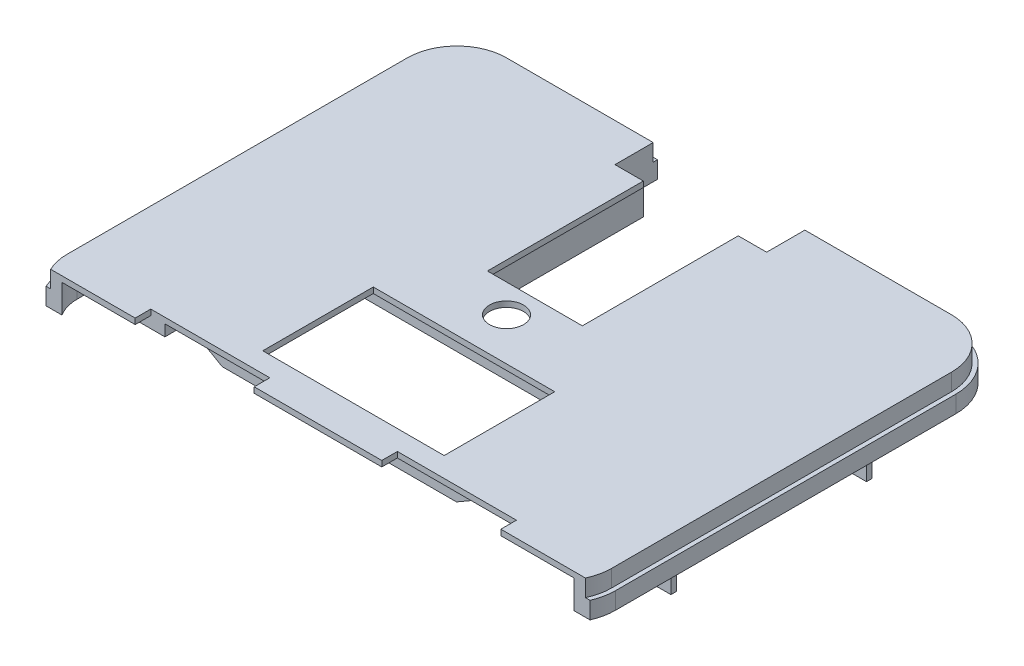
from build123d import *

# Parameters (mm, degrees)
BOSS_EXTRUDE1_DEPTH     = 2
SKETCH2_W               = 45
SKETCH2_H               = 5
BOSS_EXTRUDE2_DEPTH     = 10
BOSS_EXTRUDE3_DEPTH     = 20
SKETCH4_W               = 67
SKETCH4_H               = 2
BOSS_EXTRUDE4_DEPTH     = 5
SKETCH5_W               = 58
SKETCH5_H               = 72.3
SKETCH5_W_2             = 55
SKETCH5_H_2             = 69.3
BOSS_EXTRUDE5_DEPTH     = 19
SKETCH6_W               = 13
SKETCH6_H               = 13
SKETCH6_W_2             = 10
CUT_EXTRUDE1_DEPTH      = 1.5
BOSS_EXTRUDE6_DEPTH     = 10
CUT_EXTRUDE2_START      = -6
SKETCH9_W               = 45
SKETCH9_H               = 1.5
CUT_EXTRUDE2_DEPTH      = 7
CUT_EXTRUDE3_DEPTH      = 12
SKETCH11_R              = 2.5
SKETCH11_R_2            = 1.5
BOSS_EXTRUDE7_DEPTH     = 4
SKETCH12_W              = 34
SKETCH12_H              = 63
SKETCH12_W_2            = 32
SKETCH12_H_2            = 61
BOSS_EXTRUDE8_DEPTH     = 4
SKETCH13_W              = 8
SKETCH13_H              = 4
CUT_EXTRUDE4_DEPTH      = 18
SKETCH14_R              = 6
SKETCH14_W              = 64
SKETCH14_H              = 39
CUT_EXTRUDE5_DEPTH      = 21
CUT_EXTRUDE5_DEPTH_BACK = 3
SKETCH15_W              = 100
SKETCH15_H              = 3
SKETCH15_W_2            = 112
BOSS_EXTRUDE9_DEPTH     = 5
CUT_EXTRUDE6_DEPTH      = 5


with BuildPart() as part:
    # Sketch1 → Boss-Extrude1 (new body)
    with BuildSketch(Plane(origin=(0, 0, 0), x_dir=(1, 0, 0), z_dir=(0, 1, 0))):
        with BuildLine():
            Line((124.25, 158), (176, 158))
            ThreePointArc((176, 158), (189.435028843, 152.435028843), (195, 139))
            Line((195, 139), (195, 19))
            ThreePointArc((195, 19), (189.435028843, 5.564971157), (176, 0))
            Line((176, 0), (162, 0))
            Line((162, 0), (162, 17))
            Line((162, 17), (120, 17))
            Line((120, 17), (120, 0))
            Line((120, 0), (75, 0))
            Line((75, 0), (75, 17))
            Line((75, 17), (33, 17))
            Line((33, 17), (33, 0))
            Line((33, 0), (19, 0))
            ThreePointArc((19, 0), (5.564971157, 5.564971157), (0, 19))
            Line((0, 19), (0, 139))
            ThreePointArc((0, 139), (5.564971157, 152.435028843), (19, 158))
            Line((19, 158), (70.75, 158))
            Line((70.75, 158), (70.75, 143))
            Line((70.75, 143), (80.75, 143))
            Line((80.75, 143), (80.75, 88))
            Line((80.75, 88), (114.25, 88))
            Line((114.25, 88), (114.25, 143))
            Line((114.25, 143), (124.25, 143))
            Line((124.25, 143), (124.25, 158))
        make_face()
    extrude(amount=BOSS_EXTRUDE1_DEPTH)

    # Sketch2 → Boss-Extrude2 (add)
    with BuildSketch(Plane.XZ):
        with Locations((97.5, -2.5)):
            Rectangle(SKETCH2_W, SKETCH2_H)
        with BuildLine():
            Line((33, 0), (33, -5))
            Line((33, -5), (19, -5))
            ThreePointArc((19, -5), (9.100505063, -9.100505063), (5, -19))
            Line((5, -19), (5, -139))
            ThreePointArc((5, -139), (9.100505063, -148.899494937), (19, -153))
            Line((19, -153), (70.75, -153))
            Line((70.75, -153), (70.75, -158))
            Line((70.75, -158), (19, -158))
            ThreePointArc((19, -158), (5.564971157, -152.435028843), (0, -139))
            Line((0, -139), (0, -19))
            ThreePointArc((0, -19), (5.564971157, -5.564971157), (19, 0))
            Line((19, 0), (33, 0))
        make_face()
        with BuildLine():
            Line((162, 0), (162, -5))
            Line((162, -5), (176, -5))
            ThreePointArc((176, -5), (185.899494937, -9.100505063), (190, -19))
            Line((190, -19), (190, -139))
            ThreePointArc((190, -139), (185.899494937, -148.899494937), (176, -153))
            Line((176, -153), (124.25, -153))
            Line((124.25, -153), (124.25, -158))
            Line((124.25, -158), (176, -158))
            ThreePointArc((176, -158), (189.435028843, -152.435028843), (195, -139))
            Line((195, -139), (195, -19))
            ThreePointArc((195, -19), (189.435028843, -5.564971157), (176, 0))
            Line((176, 0), (162, 0))
        make_face()
    extrude(amount=BOSS_EXTRUDE2_DEPTH)

    # Sketch3 → Boss-Extrude3 (add)
    with BuildSketch(Plane.XZ):
        Polygon((190, -43.5), (150, -43.5), (150, -114.5), (190, -114.5), (190, -112.5), (152, -112.5), (152, -45.5), (190, -45.5), align=None)
    extrude(amount=BOSS_EXTRUDE3_DEPTH)

    # Sketch4 → Boss-Extrude4 (add)
    with BuildSketch(Plane(origin=(152, 0, 0), x_dir=(0, 0, -1), z_dir=(1, 0, 0))):
        with Locations((79, -19)):
            Rectangle(SKETCH4_W, SKETCH4_H)
    extrude(amount=BOSS_EXTRUDE4_DEPTH)

    # Sketch5 → Boss-Extrude5 (add)
    with BuildSketch(Plane.XZ):
        with Locations((41.75, -116.85)):
            Rectangle(SKETCH5_W, SKETCH5_H)
        with Locations((41.75, -116.85)):
            Rectangle(SKETCH5_W_2, SKETCH5_H_2, mode=Mode.SUBTRACT)
    extrude(amount=BOSS_EXTRUDE5_DEPTH)

    # Sketch6 → Cut-Extrude1 (cut)
    with BuildSketch(Plane.XY.offset(-80.7)):
        with Locations((52.25, -9.5)):
            Rectangle(SKETCH6_W, SKETCH6_H)
        with Locations((20.75, -9.5)):
            Rectangle(SKETCH6_W_2, SKETCH6_H)
    extrude(amount=-CUT_EXTRUDE1_DEPTH, mode=Mode.SUBTRACT)

    # Sketch8 → Boss-Extrude6 (add, symmetric)
    with BuildSketch(Plane(origin=(29.25, 0, 0), x_dir=(0, 0, -1), z_dir=(1, 0, 0))):
        Polygon((151.5, -3.5), (150.5, -3.5), (151.5, -9.5), align=None)
    extrude(amount=BOSS_EXTRUDE6_DEPTH, both=True)

    # Sketch9 → Cut-Extrude2 (cut, through all)
    with BuildSketch(Plane.XZ.offset(10).offset(CUT_EXTRUDE2_START)):
        with BuildLine():
            ThreePointArc((0, -139), (5.564971157, -152.435028843), (19, -158))
            Line((19, -158), (70.75, -158))
            Line((70.75, -158), (70.75, -156.5))
            Line((70.75, -156.5), (19, -156.5))
            ThreePointArc((19, -156.5), (6.625631329, -151.374368671), (1.5, -139))
            Line((1.5, -139), (1.5, -19))
            ThreePointArc((1.5, -19), (6.625631329, -6.625631329), (19, -1.5))
            Line((19, -1.5), (33, -1.5))
            Line((33, -1.5), (33, 0))
            Line((33, 0), (19, 0))
            ThreePointArc((19, 0), (5.564971157, -5.564971157), (0, -19))
            Line((0, -19), (0, -139))
        make_face()
        with BuildLine():
            ThreePointArc((193.5, -19), (188.374368671, -6.625631329), (176, -1.5))
            Line((176, -1.5), (162, -1.5))
            Line((162, -1.5), (162, 0))
            Line((162, 0), (176, 0))
            ThreePointArc((176, 0), (189.435028843, -5.564971157), (195, -19))
            Line((195, -19), (195, -139))
            ThreePointArc((195, -139), (189.435028843, -152.435028843), (176, -158))
            Line((176, -158), (124.25, -158))
            Line((124.25, -158), (124.25, -156.5))
            Line((124.25, -156.5), (176, -156.5))
            ThreePointArc((176, -156.5), (188.374368671, -151.374368671), (193.5, -139))
            Line((193.5, -139), (193.5, -19))
        make_face()
        with Locations((97.5, -0.75)):
            Rectangle(SKETCH9_W, SKETCH9_H)
    extrude(amount=-CUT_EXTRUDE2_DEPTH, mode=Mode.SUBTRACT)

    # Sketch10 → Cut-Extrude3 (cut)
    with BuildSketch(Plane(origin=(0, 2, 0), x_dir=(1, 0, 0), z_dir=(0, 1, 0))):
        with BuildLine():
            Line((176, 0), (19, 0))
            ThreePointArc((19, 0), (8.54772752, 3.133368347), (1.54290975, 11.5))
            Line((1.54290975, 11.5), (193.45709025, 11.5))
            ThreePointArc((193.45709025, 11.5), (186.45227248, 3.133368347), (176, 0))
        make_face()
    extrude(amount=-CUT_EXTRUDE3_DEPTH, mode=Mode.SUBTRACT)

    # Sketch11 → Boss-Extrude7 (add)
    with BuildSketch(Plane.XZ):
        with Locations(Location((185, -119.5, 0), (0, 0, 90))):  # turned: the seam where the file's is
            Circle(SKETCH11_R)
        with Locations(Location((185, -119.5, 0), (0, 0, 270))):  # turned: the seam where the file's is
            Circle(SKETCH11_R_2, mode=Mode.SUBTRACT)
        with Locations(Location((185, -135.5, 0), (0, 0, 90))):  # turned: the seam where the file's is
            Circle(SKETCH11_R)
        with Locations(Location((185, -135.5, 0), (0, 0, 270))):  # turned: the seam where the file's is
            Circle(SKETCH11_R_2, mode=Mode.SUBTRACT)
        with Locations(Location((185, -38.5, 0), (0, 0, 90))):  # turned: the seam where the file's is
            Circle(SKETCH11_R)
        with Locations(Location((185, -38.5, 0), (0, 0, 90))):  # turned: the seam where the file's is
            Circle(SKETCH11_R_2, mode=Mode.SUBTRACT)
        with Locations(Location((185, -22.5, 0), (0, 0, 90))):  # turned: the seam where the file's is
            Circle(SKETCH11_R)
        with Locations(Location((185, -22.5, 0), (0, 0, 90))):  # turned: the seam where the file's is
            Circle(SKETCH11_R_2, mode=Mode.SUBTRACT)
    extrude(amount=BOSS_EXTRUDE7_DEPTH)

    # Sketch12 → Boss-Extrude8 (add)
    with BuildSketch(Plane.XZ):
        with Locations((21, -48.5)):
            Rectangle(SKETCH12_W, SKETCH12_H)
        with Locations((21, -48.5)):
            Rectangle(SKETCH12_W_2, SKETCH12_H_2, mode=Mode.SUBTRACT)
    extrude(amount=BOSS_EXTRUDE8_DEPTH)

    # Sketch13 → Cut-Extrude4 (cut)
    with BuildSketch(Plane(origin=(5, 0, 0), x_dir=(0, 0, -1), z_dir=(1, 0, 0))):
        with Locations((67, -4)):
            Rectangle(SKETCH13_W, SKETCH13_H)
    extrude(amount=-CUT_EXTRUDE4_DEPTH, mode=Mode.SUBTRACT)

    # Sketch14 → Cut-Extrude5 (cut, two sides)
    with BuildSketch(Plane.XZ) as cut_extrude5_sk:
        with Locations(Location((97.5, -78, 0), (0, 0, 270))):  # turned: the seam where the file's is
            Circle(SKETCH14_R)
        with Locations((97.5, -43.5)):
            Rectangle(SKETCH14_W, SKETCH14_H)
    extrude(amount=CUT_EXTRUDE5_DEPTH, mode=Mode.SUBTRACT)
    extrude(cut_extrude5_sk.sketch, amount=-CUT_EXTRUDE5_DEPTH_BACK, mode=Mode.SUBTRACT)

    # Sketch15 → Boss-Extrude9 (add)
    with BuildSketch(Plane.XZ):
        with Locations((97.5, -20.5)):
            Rectangle(SKETCH15_W, SKETCH15_H)
        with Locations((94, -66.5)):
            Rectangle(SKETCH15_W_2, SKETCH15_H)
    extrude(amount=BOSS_EXTRUDE9_DEPTH)

    # Sketch16 → Cut-Extrude6 (cut)
    with BuildSketch(Plane(origin=(0, 0, -22), x_dir=(-1, 0, 0), z_dir=(0, 0, -1))):
        Polygon((-47.5, 0), (-56.160254038, -5), (-47.5, -5), align=None)
        Polygon((-147.5, 0), (-138.839745962, -5), (-147.5, -5), align=None)
    extrude(amount=-CUT_EXTRUDE6_DEPTH, mode=Mode.SUBTRACT)


solid = part.part
